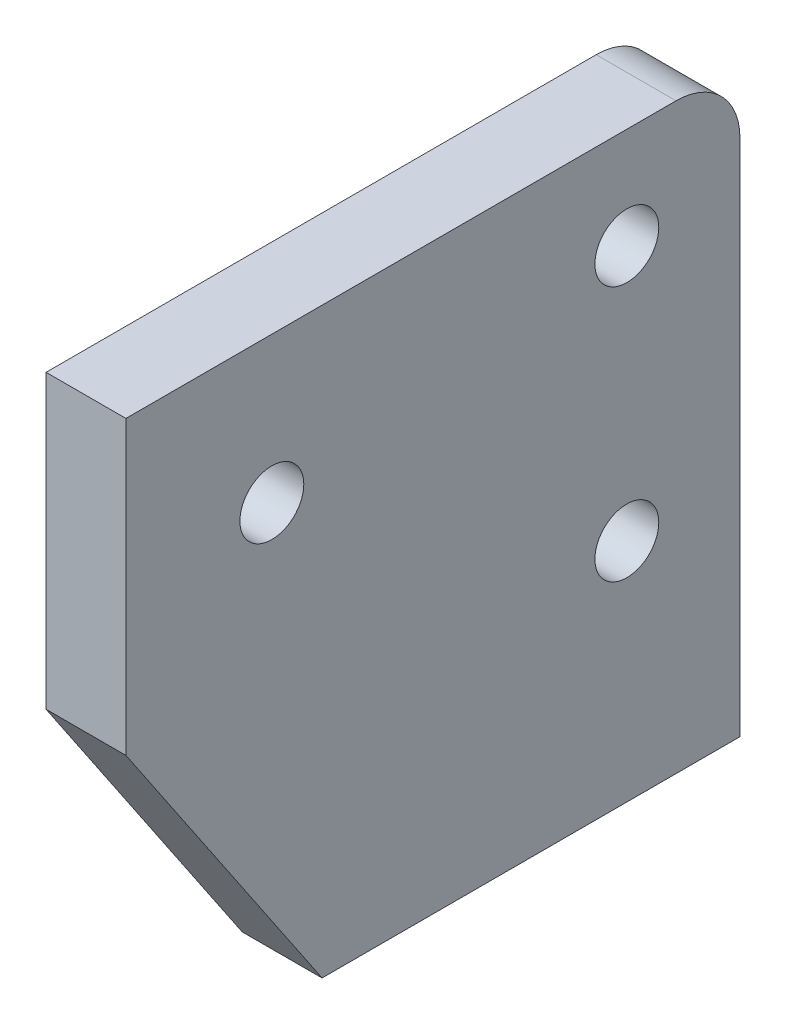
from build123d import *

# Parameters (mm, degrees)
SKETCH1_R           = 1.27
BOSS_EXTRUDE1_DEPTH = 3.175
FILLET3_R           = 2.54


with BuildPart() as part:
    # Sketch1 → Boss-Extrude1 (new body)
    with BuildSketch(Plane(origin=(0, 0, 0), x_dir=(0, 0, -1), z_dir=(1, 0, 0))):
        Polygon((0.846258814, 2.623762197), (9.840144814, 2.623762197), (9.840144814, 25.789873149), (0.846258814, 25.789873149), (-14.571831472, 25.789873149), (-14.571831472, 14.187329911), (-6.773741186, 2.623762197), align=None)
        with Locations((5.343201814, 21.777648197)):
            Circle(SKETCH1_R, mode=Mode.SUBTRACT)
        with Locations((5.343201814, 11.617648197)):
            Circle(SKETCH1_R, mode=Mode.SUBTRACT)
        with Locations((-8.770559864, 19.98860153)):
            Circle(SKETCH1_R, mode=Mode.SUBTRACT)
    extrude(amount=BOSS_EXTRUDE1_DEPTH)

    # Fillet3
    fillet3_edges = [part.edges().sort_by_distance(p)[0] for p in [
        (1.5875, 25.789873149, -9.840144814),
    ]]
    fillet(fillet3_edges, radius=FILLET3_R)


solid = part.part
